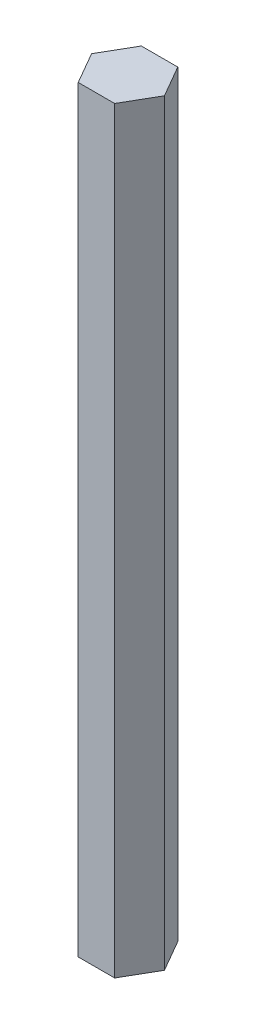
from build123d import *

# Parameters (mm, degrees)
BOSS_EXTRUDE1_DEPTH = 152.4


with BuildPart() as part:
    # Sketch1 → Boss-Extrude1 (new body)
    with BuildSketch(Plane(origin=(0, 0, 0), x_dir=(1, 0, 0), z_dir=(0, 1, 0))):
        Polygon((3.666174209, -6.35), (7.332348419, 0), (3.666174209, 6.35), (-3.666174209, 6.35), (-7.332348419, 0), (-3.666174209, -6.35), align=None)
    extrude(amount=BOSS_EXTRUDE1_DEPTH)


solid = part.part
